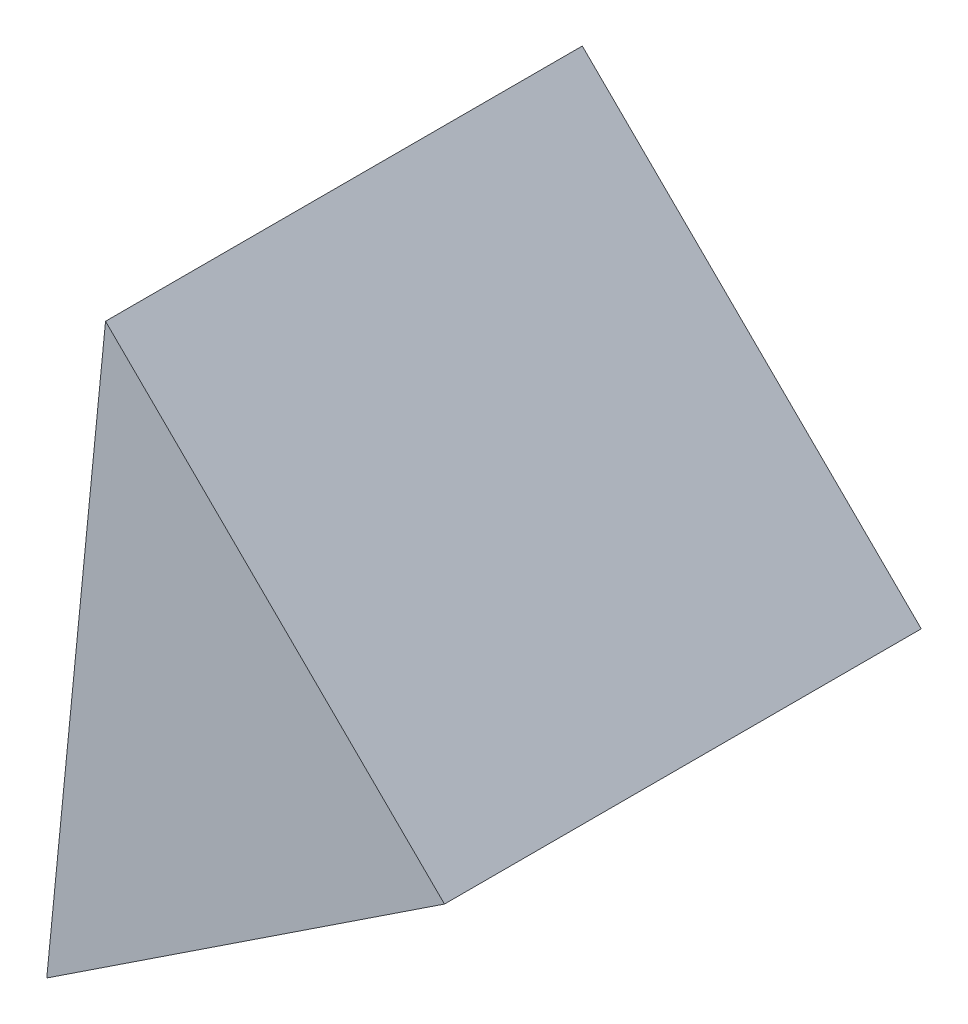
from build123d import *

# Parameters (mm, degrees)
EXTRUDE_1_DEPTH = 5


with BuildPart() as part:
    # 草图2 → 凸台-拉伸1 (new body)
    with BuildSketch(Plane.XY):
        Polygon((4.857370913, 3.604478735), (1.302506795, 7.12057616), (0.686170974, 0.847471105), align=None)
    extrude(amount=EXTRUDE_1_DEPTH)


solid = part.part
